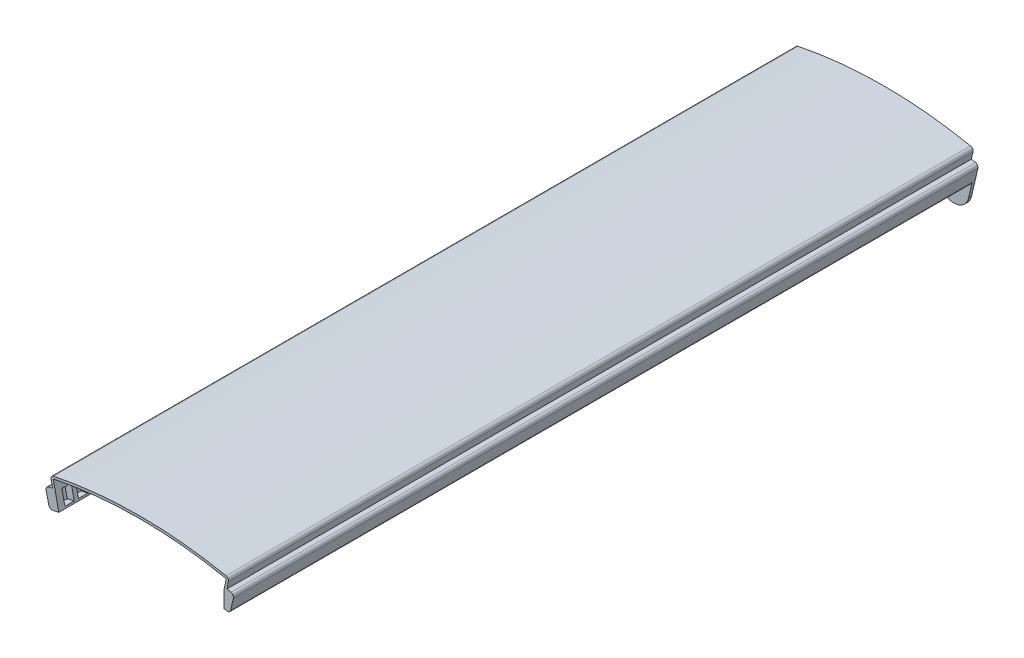
from build123d import *

# Parameters (mm, degrees)
SKETCH1_R           = 2
BACK_DEPTH          = 2
SIDES_DEPTH         = 492
FIRST_NOTCH_DEPTH   = 4.5
SECOND_START        = 10.7
SECOND_NOTCH_DEPTH  = 2.8
LPATTERN1_COUNT     = 53
LPATTERN1_PITCH     = 9
BOSS_EXTRUDE5_START = 492
BOSS_EXTRUDE5_DEPTH = 4.3
FILLET2_R           = 2


with BuildPart() as part:
    # Sketch1 → Back (new body)
    with BuildSketch(Plane.XY):
        with BuildLine():
            Line((-1.658894516, 267.294852305), (-10, 284.924568965))
            ThreePointArc((-10, 284.924568965), (0, 285.1), (10, 284.924568965))
            Line((10, 284.924568965), (1.658894516, 267.294852305))
            Line((1.658894516, 267.294852305), (0.1, 263.999981061))
            ThreePointArc((0.1, 263.999981061), (19.766973476, 263.258934814), (39.324091011, 261.054813911))
            Line((39.324091011, 261.054813911), (38.57931656, 256.110593951))
            ThreePointArc((38.57931656, 256.110593951), (46.468675498, 244.757564238), (57.969972971, 252.429162804))
            Line((57.969972971, 252.429162804), (62.151767837, 270.542506373))
            ThreePointArc((62.151767837, 270.542506373), (61.881664512, 272.135422136), (60.560279967, 273.065088377))
            ThreePointArc((60.560279967, 273.065088377), (59.210573587, 273.360929863), (57.859422191, 273.650100062))
            Line((57.859422191, 273.650100062), (58.876118934, 278.433282169))
            ThreePointArc((58.876118934, 278.433282169), (58.578378942, 280.021054628), (57.241285918, 280.927615564))
            ThreePointArc((57.241285918, 280.927615564), (0, 286.7), (-57.241285918, 280.927615564))
            ThreePointArc((-57.241285918, 280.927615564), (-58.578378942, 280.021054628), (-58.876118934, 278.433282169))
            Line((-58.876118934, 278.433282169), (-57.859422191, 273.650100062))
            ThreePointArc((-57.859422191, 273.650100062), (-59.210573587, 273.360929863), (-60.560279967, 273.065088377))
            ThreePointArc((-60.560279967, 273.065088377), (-61.881664512, 272.135422136), (-62.151767837, 270.542506373))
            Line((-62.151767837, 270.542506373), (-57.969972971, 252.429162804))
            ThreePointArc((-57.969972971, 252.429162804), (-46.468675498, 244.757564238), (-38.57931656, 256.110593951))
            Line((-38.57931656, 256.110593951), (-39.418315615, 261.040602961))
            ThreePointArc((-39.418315615, 261.040602961), (-19.814484524, 263.255363104), (-0.1, 263.999981061))
            Line((-0.1, 263.999981061), (-1.658894516, 267.294852305))
        make_face()
        with Locations((-48.309725326, 254.454653011)):
            Circle(SKETCH1_R, mode=Mode.SUBTRACT)
        with Locations((48.309725326, 254.454653011)):
            Circle(SKETCH1_R, mode=Mode.SUBTRACT)
    extrude(amount=-BACK_DEPTH)

    # Sketch1_3 → Sides (add)
    with BuildSketch(Plane.XY):
        with BuildLine():
            Line((60.307098151, 262.552364134), (62.151767837, 270.542506373))
            ThreePointArc((62.151767837, 270.542506373), (61.881664512, 272.135422136), (60.560279967, 273.065088377))
            ThreePointArc((60.560279967, 273.065088377), (59.210573587, 273.360929863), (57.859422191, 273.650100062))
            Line((57.859422191, 273.650100062), (58.876118934, 278.433282169))
            ThreePointArc((58.876118934, 278.433282169), (58.578378942, 280.021054628), (57.241285918, 280.927615564))
            ThreePointArc((57.241285918, 280.927615564), (0, 286.7), (-57.241285918, 280.927615564))
            ThreePointArc((-57.241285918, 280.927615564), (-58.578378942, 280.021054628), (-58.876118934, 278.433282169))
            Line((-58.876118934, 278.433282169), (-57.859422191, 273.650100062))
            ThreePointArc((-57.859422191, 273.650100062), (-59.210573587, 273.360929863), (-60.560279967, 273.065088377))
            ThreePointArc((-60.560279967, 273.065088377), (-61.881664512, 272.135422136), (-62.151767837, 270.542506373))
            Line((-62.151767837, 270.542506373), (-60.307098151, 262.552364134))
            ThreePointArc((-60.307098151, 262.552364134), (-59.381673252, 261.248834992), (-57.806771297, 260.974456973))
            ThreePointArc((-57.806771297, 260.974456973), (-55.762548674, 261.418874922), (-53.714910529, 261.847280656))
            Line((-53.714910529, 261.847280656), (-53.964410833, 263.021087298))
            ThreePointArc((-53.964410833, 263.021087298), (-56.257618888, 262.540149914), (-58.546542709, 262.039219082))
            Line((-58.546542709, 262.039219082), (-60.592775733, 270.90242806))
            ThreePointArc((-60.592775733, 270.90242806), (-60.528465418, 271.281693718), (-60.21385005, 271.503042823))
            ThreePointArc((-60.21385005, 271.503042823), (-58.088906761, 271.965602441), (-55.960411314, 272.411531264))
            Line((-55.960411314, 272.411531264), (-57.311082773, 278.765940874))
            ThreePointArc((-57.311082773, 278.765940874), (-57.240192298, 279.143981936), (-56.921836817, 279.359829778))
            ThreePointArc((-56.921836817, 279.359829778), (0, 285.1), (56.921836817, 279.359829778))
            ThreePointArc((56.921836817, 279.359829778), (57.240192298, 279.143981936), (57.311082773, 278.765940874))
            Line((57.311082773, 278.765940874), (55.960411314, 272.411531264))
            ThreePointArc((55.960411314, 272.411531264), (58.088906761, 271.965602441), (60.21385005, 271.503042823))
            ThreePointArc((60.21385005, 271.503042823), (60.528465418, 271.281693718), (60.592775733, 270.90242806))
            Line((60.592775733, 270.90242806), (58.546542709, 262.039219082))
            ThreePointArc((58.546542709, 262.039219082), (57.300647303, 262.314478858), (56.053457906, 262.583814918))
            Line((56.053457906, 262.583814918), (55.802939658, 261.410255969))
            ThreePointArc((55.802939658, 261.410255969), (56.8052734, 261.194278103), (57.806771297, 260.974456973))
            ThreePointArc((57.806771297, 260.974456973), (59.381673252, 261.248834992), (60.307098151, 262.552364134))
        make_face()
    extrude(amount=SIDES_DEPTH)

    # Sketch1_4 → First notch (add)
    with BuildSketch(Plane.XY):
        with BuildLine():
            ThreePointArc((-58.546542709, 262.039219082), (-56.257618888, 262.540149914), (-53.964410833, 263.021087298))
            Line((-53.964410833, 263.021087298), (-55.960411314, 272.411531264))
            ThreePointArc((-55.960411314, 272.411531264), (-58.088906761, 271.965602441), (-60.21385005, 271.503042823))
            ThreePointArc((-60.21385005, 271.503042823), (-60.528465418, 271.281693718), (-60.592775733, 270.90242806))
            Line((-60.592775733, 270.90242806), (-58.546542709, 262.039219082))
        make_face()
        with BuildLine():
            ThreePointArc((56.053457906, 262.583814918), (57.300647303, 262.314478858), (58.546542709, 262.039219082))
            Line((58.546542709, 262.039219082), (60.592775733, 270.90242806))
            ThreePointArc((60.592775733, 270.90242806), (60.528465418, 271.281693718), (60.21385005, 271.503042823))
            ThreePointArc((60.21385005, 271.503042823), (58.088906761, 271.965602441), (55.960411314, 272.411531264))
            Line((55.960411314, 272.411531264), (56.053457906, 262.583814918))
        make_face()
    extrude(amount=FIRST_NOTCH_DEPTH)

    # Sketch1_5 → Second notch (add)
    with BuildSketch(Plane.XY.offset(SECOND_START)):
        with BuildLine():
            ThreePointArc((-58.546542709, 262.039219082), (-56.257618888, 262.540149914), (-53.964410833, 263.021087298))
            Line((-53.964410833, 263.021087298), (-55.960411314, 272.411531264))
            ThreePointArc((-55.960411314, 272.411531264), (-58.088906761, 271.965602441), (-60.21385005, 271.503042823))
            ThreePointArc((-60.21385005, 271.503042823), (-60.528465418, 271.281693718), (-60.592775733, 270.90242806))
            Line((-60.592775733, 270.90242806), (-58.546542709, 262.039219082))
        make_face()
        with BuildLine():
            ThreePointArc((56.053457906, 262.583814918), (57.300647303, 262.314478858), (58.546542709, 262.039219082))
            Line((58.546542709, 262.039219082), (60.592775733, 270.90242806))
            ThreePointArc((60.592775733, 270.90242806), (60.528465418, 271.281693718), (60.21385005, 271.503042823))
            ThreePointArc((60.21385005, 271.503042823), (58.088906761, 271.965602441), (55.960411314, 272.411531264))
            Line((55.960411314, 272.411531264), (56.053457906, 262.583814918))
        make_face()
    second_notch = extrude(amount=SECOND_NOTCH_DEPTH)

    # LPattern1: Second notch ×53
    with Locations(*[(0, 0, i * LPATTERN1_PITCH) for i in range(1, LPATTERN1_COUNT)]):
        add(second_notch)

    # Sketch1_6 → Boss-Extrude5 (add)
    with BuildSketch(Plane.XY.offset(BOSS_EXTRUDE5_START)):
        with BuildLine():
            ThreePointArc((-58.546542709, 262.039219082), (-56.257618888, 262.540149914), (-53.964410833, 263.021087298))
            Line((-53.964410833, 263.021087298), (-55.960411314, 272.411531264))
            ThreePointArc((-55.960411314, 272.411531264), (-58.088906761, 271.965602441), (-60.21385005, 271.503042823))
            ThreePointArc((-60.21385005, 271.503042823), (-60.528465418, 271.281693718), (-60.592775733, 270.90242806))
            Line((-60.592775733, 270.90242806), (-58.546542709, 262.039219082))
        make_face()
        with BuildLine():
            ThreePointArc((56.053457906, 262.583814918), (57.300647303, 262.314478858), (58.546542709, 262.039219082))
            Line((58.546542709, 262.039219082), (60.592775733, 270.90242806))
            ThreePointArc((60.592775733, 270.90242806), (60.528465418, 271.281693718), (60.21385005, 271.503042823))
            ThreePointArc((60.21385005, 271.503042823), (58.088906761, 271.965602441), (55.960411314, 272.411531264))
            Line((55.960411314, 272.411531264), (56.053457906, 262.583814918))
        make_face()
    extrude(amount=-BOSS_EXTRUDE5_DEPTH)

    # Fillet2
    fillet2_edges = [part.edges().sort_by_distance(p)[0] for p in [
        (10, 284.924568965, -1),
        (-10, 284.924568965, -1),
        (0.1, 263.999981061, -1),
        (-0.1, 263.999981061, -1),
    ]]
    fillet(fillet2_edges, radius=FILLET2_R)


solid = part.part
